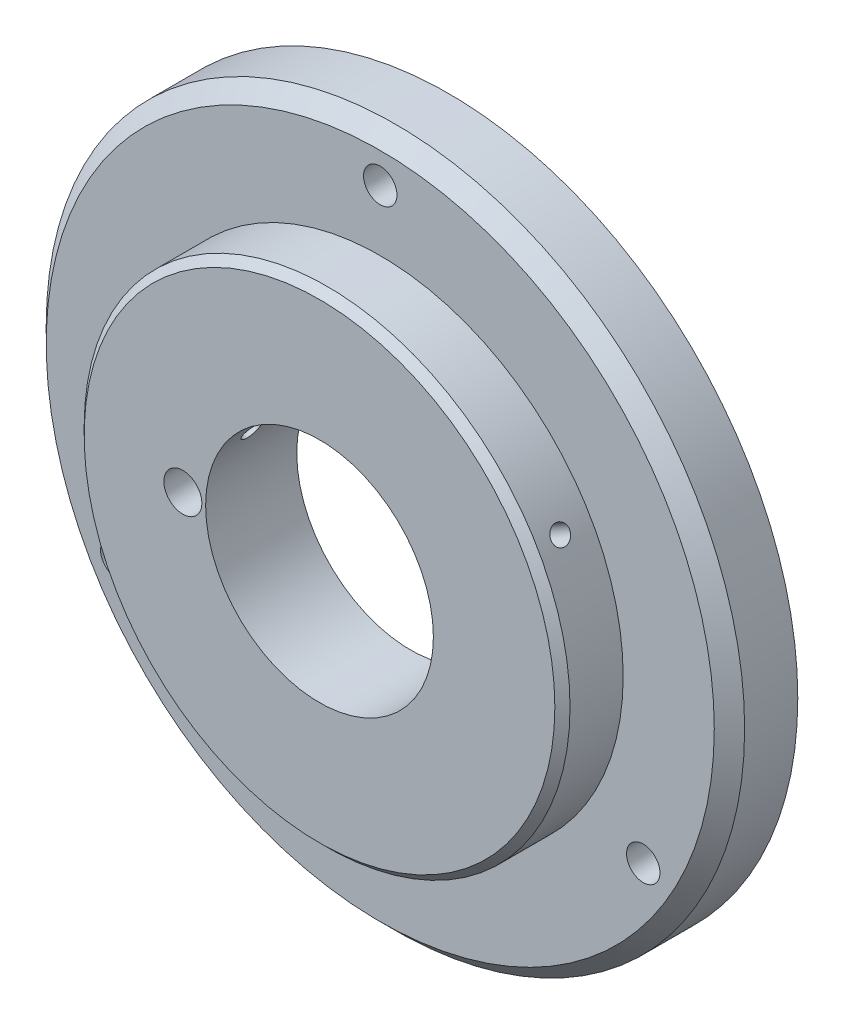
from build123d import *

# Parameters (mm, degrees)
ESQUISSE1_R                  = 46
BASE_EXTRUSION_DEPTH         = 9
ESQUISSE2_R                  = 32
BOSS_EXTRU_1_DEPTH           = 8
ESQUISSE3_R                  = 26
ENL_V_MAT_EXTRU_1_DEPTH      = 5
ESQUISSE4_R                  = 15
ENL_V_MAT_EXTRU_2_DEPTH      = 13
ESQUISSE5_R                  = 2.2
ENL_V_MAT_EXTRU_3_DEPTH      = 10
R_P_TITION_CIRCULAIRE1_COUNT = 3
CHANFREIN1_SIZE              = 2
CHANFREIN2_SIZE              = 1
ENL_V_START                  = -17.050105
ESQUISSE8_R                  = 1.225
ENL_V_MAT_EXTRU_4_DEPTH      = 17.050105
R_P_TITION_CIRCULAIRE2_COUNT = 2
R_P_TITION_CIRCULAIRE2_ANGLE = 120
ESQUISSE9_R                  = 2.5
ENL_V_MAT_EXTRU_5_DEPTH      = 18


with BuildPart() as part:
    # Esquisse1 → Base-Extrusion (new body)
    with BuildSketch(Plane.XY):
        Circle(ESQUISSE1_R)
    extrude(amount=BASE_EXTRUSION_DEPTH)

    # Esquisse2 → Boss.-Extru.1 (add)
    with BuildSketch(Plane.XY.offset(9)):
        Circle(ESQUISSE2_R)
    extrude(amount=BOSS_EXTRU_1_DEPTH)

    # Esquisse3 → Enlèv. mat.-Extru.1 (cut)
    with BuildSketch(Plane(origin=(0, 0, 0), x_dir=(-1, 0, 0), z_dir=(0, 0, -1))):
        Circle(ESQUISSE3_R)
    extrude(amount=-ENL_V_MAT_EXTRU_1_DEPTH, mode=Mode.SUBTRACT)

    # Esquisse4 → Enlèv. mat.-Extru.2 (cut, through all)
    with BuildSketch(Plane(origin=(0, 0, 5), x_dir=(-1, 0, 0), z_dir=(0, 0, -1))):
        Circle(ESQUISSE4_R)
    extrude(amount=-ENL_V_MAT_EXTRU_2_DEPTH, mode=Mode.SUBTRACT)

    # Esquisse5 → Enlèv. mat.-Extru.3 (cut, through all)
    with BuildSketch(Plane.XY.offset(9)):
        with Locations((0, 40)):
            Circle(ESQUISSE5_R)
    enl_v_mat_extru_3 = extrude(amount=-ENL_V_MAT_EXTRU_3_DEPTH, mode=Mode.SUBTRACT)

    # Répétition circulaire1: Enlèv. mat.-Extru.3 ×3 about axis
    r_p_tition_circulaire1_axis = Axis((0, 0, 0), (0, 0, 1))
    for i in range(1, R_P_TITION_CIRCULAIRE1_COUNT):
        add(enl_v_mat_extru_3.rotate(r_p_tition_circulaire1_axis, i * 360 / R_P_TITION_CIRCULAIRE1_COUNT), mode=Mode.SUBTRACT)

    # Chanfrein1
    chanfrein1_edges = [part.edges().sort_by_distance(p)[0] for p in [
        (-46, 0, 9),
    ]]
    chamfer(chanfrein1_edges, length=CHANFREIN1_SIZE)

    # Chanfrein2
    chanfrein2_edges = [part.edges().sort_by_distance(p)[0] for p in [
        (-32, 0, 17),
    ]]
    chamfer(chanfrein2_edges, length=CHANFREIN2_SIZE)

    # Esquisse8 → Enlèv. mat.-Extru.4 (cut)
    with BuildSketch(Plane(origin=(27.712812921, 16, 0), x_dir=(0, 0, -1), z_dir=(0.866025404, 0.5, 0)).offset(ENL_V_START)):
        with Locations((-13, 0)):
            Circle(ESQUISSE8_R)
    enl_v_mat_extru_4 = extrude(amount=ENL_V_MAT_EXTRU_4_DEPTH, mode=Mode.SUBTRACT)

    # Répétition circulaire2: Enlèv. mat.-Extru.4 ×2 about axis
    r_p_tition_circulaire2_axis = Axis((0, 0, 17), (0, 0, 1))
    for i in range(1, R_P_TITION_CIRCULAIRE2_COUNT):
        add(enl_v_mat_extru_4.rotate(r_p_tition_circulaire2_axis, i * R_P_TITION_CIRCULAIRE2_ANGLE / (R_P_TITION_CIRCULAIRE2_COUNT - 1)), mode=Mode.SUBTRACT)

    # Esquisse9 → Enlèv. mat.-Extru.5 (cut, through all)
    with BuildSketch(Plane.XY.offset(17)):
        with Locations((-18, 0)):
            Circle(ESQUISSE9_R)
    extrude(amount=-ENL_V_MAT_EXTRU_5_DEPTH, mode=Mode.SUBTRACT)


solid = part.part
